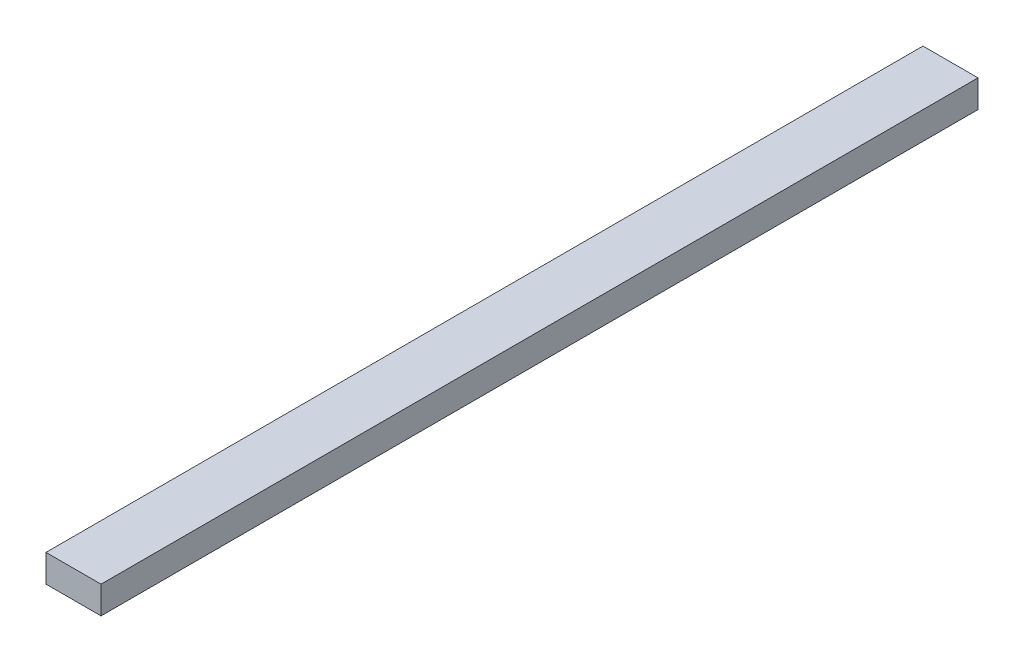
from build123d import *

# Parameters (mm, degrees)
SKETCH_1_W      = 80
SKETCH_1_H      = 40
EXTRUDE_1_DEPTH = 1275


with BuildPart() as part:
    # Эскиз1 → Бобышка-Вытянуть1 (new body)
    with BuildSketch(Plane.XY):
        with Locations((16.090225564, 2.631578947)):
            Rectangle(SKETCH_1_W, SKETCH_1_H)
    extrude(amount=EXTRUDE_1_DEPTH)


solid = part.part
